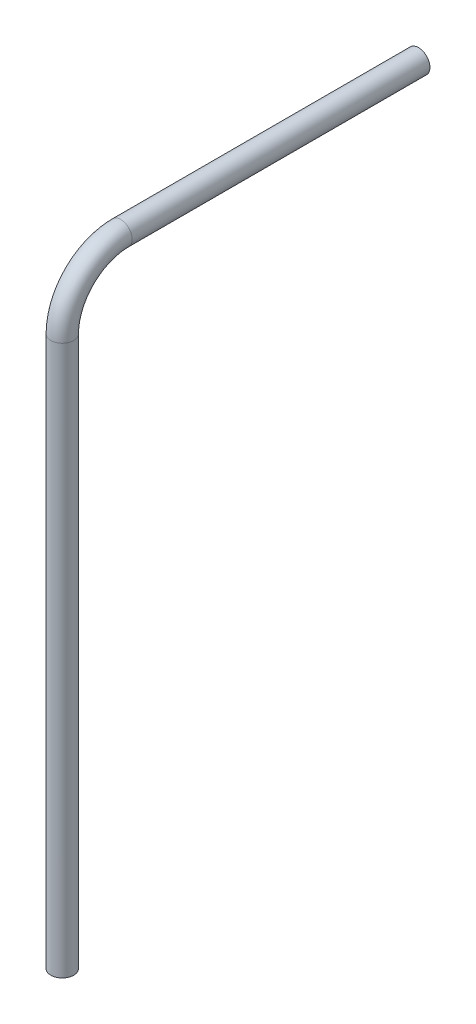
from build123d import *

# Parameters (mm, degrees)
SKETCH3_R           = 12.7
SKETCH3_R_2         = 4.7625
SKETCH4_R           = 12.7
SKETCH4_R_2         = 4.7625
BOSS_EXTRUDE3_DEPTH = 609.6
SKETCH5_R           = 12.7
SKETCH5_R_2         = 4.7625
BOSS_EXTRUDE4_DEPTH = 330.2
SKETCH6_W           = 12.7
SKETCH6_H           = 609.6
CUT_EXTRUDE1_DEPTH  = 6.35


with BuildPart() as part:
    # Sweep1: sweep along a path in Sketch2
    with BuildLine(Plane(origin=(0, 0, 0), x_dir=(0, 0, -1), z_dir=(1, 0, 0))) as sweep1_path:
        ThreePointArc((-64.833774642, 0), (-45.844401699, 45.844401699), (0, 64.833774642))
    # Sketch3 → Sweep1 (sweep)
    with BuildSketch(Plane(origin=(0, 0, 0), x_dir=(1, 0, 0), z_dir=(0, 1, 0))):
        with Locations((0, -64.833774642)):
            Circle(SKETCH3_R)
        with Locations((0, -64.833774642)):
            Circle(SKETCH3_R_2, mode=Mode.SUBTRACT)
    sweep(path=sweep1_path.line)

    # Sketch4 → Boss-Extrude3 (add)
    with BuildSketch(Plane(origin=(0, 0, 0), x_dir=(-1, 0, 0), z_dir=(0, -1, 0))):
        with Locations((0, -64.833774642)):
            Circle(SKETCH4_R)
        with Locations((0, -64.833774642)):
            Circle(SKETCH4_R_2, mode=Mode.SUBTRACT)
    extrude(amount=BOSS_EXTRUDE3_DEPTH)

    # Sketch5 → Boss-Extrude4 (add)
    with BuildSketch(Plane(origin=(0, 0, 0), x_dir=(-1, 0, 0), z_dir=(0, 0, -1))):
        with Locations((0, 64.833774642)):
            Circle(SKETCH5_R)
        with Locations((0, 64.833774642)):
            Circle(SKETCH5_R_2, mode=Mode.SUBTRACT)
    extrude(amount=BOSS_EXTRUDE4_DEPTH)

    # Sketch6 → Cut-Extrude1 (cut)
    with BuildSketch(Plane.ZY.offset(12.7)):
        with Locations((63.5, -304.8)):
            Rectangle(SKETCH6_W, SKETCH6_H)
    extrude(amount=-CUT_EXTRUDE1_DEPTH, mode=Mode.SUBTRACT)


solid = part.part
